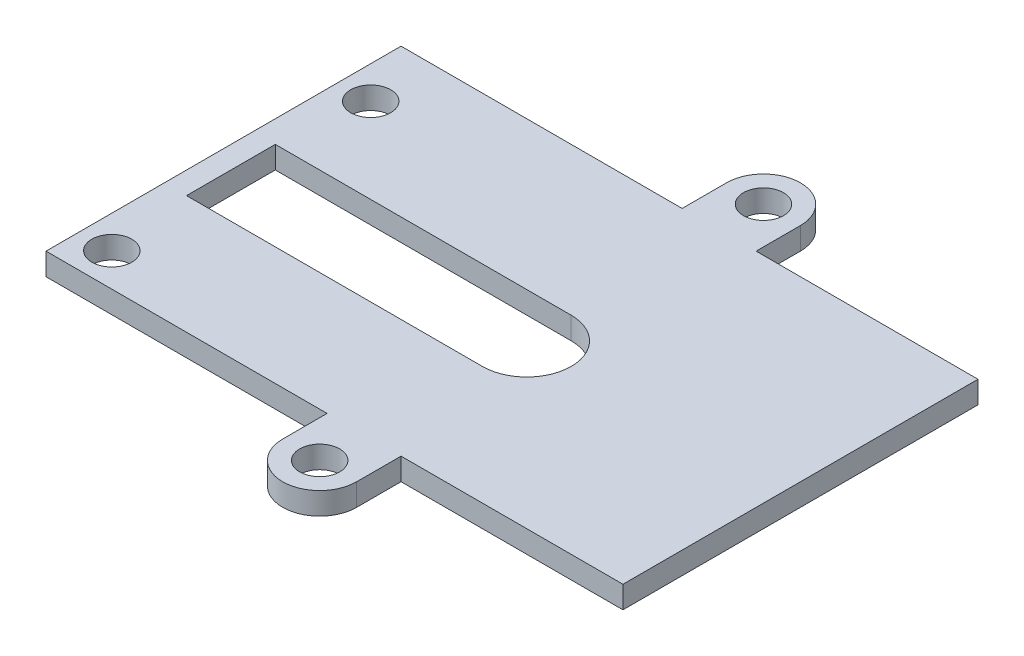
from build123d import *

# Parameters (mm, degrees)
SKETCH1_W           = 35
SKETCH1_H           = 24
SKETCH1_R           = 3
SKETCH1_R_2         = 2.5
SKETCH1_R_3         = 1.35
SKETCH1_W_2         = 4
BOSS_EXTRUDE1_DEPTH = 1.5
CUT_EXTRUDE1_DEPTH  = 10


with BuildPart() as part:
    # Sketch1 → Boss-Extrude1 (new body)
    with BuildSketch(Plane(origin=(0, 0, 0), x_dir=(1, 0, 0), z_dir=(0, 1, 0))):
        Rectangle(SKETCH1_W, SKETCH1_H)
        with Locations((0, -1)):
            Circle(SKETCH1_R, mode=Mode.SUBTRACT)
        with BuildLine():
            Line((2.5, -12), (-2.5, -12))
            Line((-2.5, -12), (-2.5, -15))
            ThreePointArc((-2.5, -15), (0, -12.5), (2.5, -15))
            Line((2.5, -15), (2.5, -12))
        make_face()
        with Locations((0, -15)):
            Circle(SKETCH1_R_2)
        with Locations((0, -15)):
            Circle(SKETCH1_R_3, mode=Mode.SUBTRACT)
        with BuildLine():
            Line((-2.5, 15), (-2.5, 12))
            Line((-2.5, 12), (2.5, 12))
            Line((2.5, 12), (2.5, 15))
            ThreePointArc((2.5, 15), (0, 12.5), (-2.5, 15))
        make_face()
        with Locations((0, 15)):
            Circle(SKETCH1_R_2)
        with Locations((0, 15)):
            Circle(SKETCH1_R_3, mode=Mode.SUBTRACT)
        with Locations((-19.5, 0)):
            Rectangle(SKETCH1_W_2, SKETCH1_H)
        with Locations((-19.3, 7.75)):
            Circle(SKETCH1_R_3, mode=Mode.SUBTRACT)
        with Locations((-19.3, -9.75)):
            Circle(SKETCH1_R_3, mode=Mode.SUBTRACT)
    extrude(amount=BOSS_EXTRUDE1_DEPTH)

    # Sketch2 → Cut-Extrude1 (cut)
    with BuildSketch(Plane(origin=(0, 1.5, 0), x_dir=(1, 0, 0), z_dir=(0, 1, 0))):
        with BuildLine():
            Line((0, 2), (-20, 2))
            Line((-20, 2), (-20, -4))
            Line((-20, -4), (0, -4))
            ThreePointArc((0, -4), (3, -1), (0, 2))
        make_face()
    extrude(amount=-CUT_EXTRUDE1_DEPTH, mode=Mode.SUBTRACT)


solid = part.part
